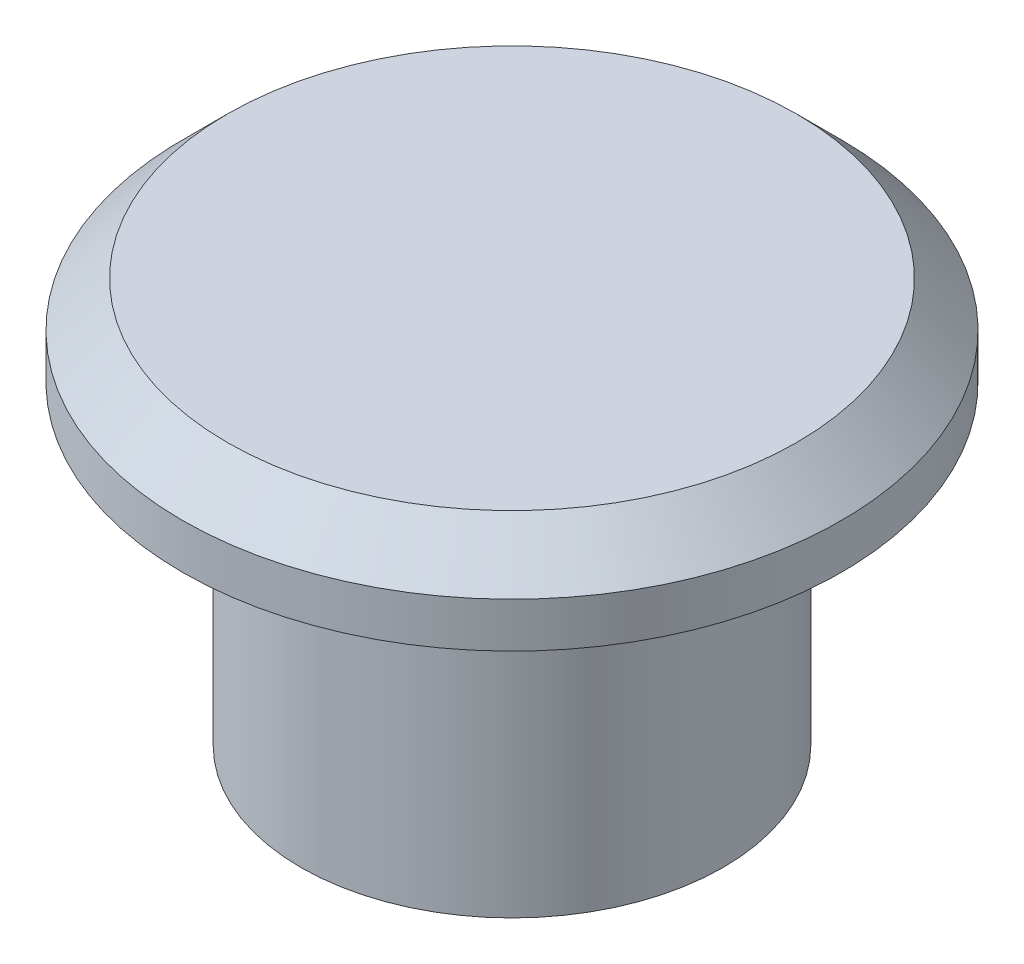
from build123d import *

# Parameters (mm, degrees)
SKETCH1_R           = 4.7
BOSS_EXTRUDE1_DEPTH = 7
SKETCH2_R           = 3.506998357
CUT_EXTRUDE1_DEPTH  = 7
SKETCH3_R           = 7.330684461
BOSS_EXTRUDE2_DEPTH = 2
CHAMFER1_SIZE       = 1


with BuildPart() as part:
    # Sketch1 → Boss-Extrude1 (new body)
    with BuildSketch(Plane(origin=(0, 0, 0), x_dir=(1, 0, 0), z_dir=(0, 1, 0))):
        Circle(SKETCH1_R)
    extrude(amount=BOSS_EXTRUDE1_DEPTH)

    # Sketch2 → Cut-Extrude1 (cut)
    with BuildSketch(Plane(origin=(0, 7, 0), x_dir=(-1, 0, 0), z_dir=(0, 1, 0))):
        Circle(SKETCH2_R)
    extrude(amount=-CUT_EXTRUDE1_DEPTH, mode=Mode.SUBTRACT)

    # Sketch3 → Boss-Extrude2 (add)
    with BuildSketch(Plane(origin=(0, 7, 0), x_dir=(1, 0, 0), z_dir=(0, 1, 0))):
        Circle(SKETCH3_R)
    extrude(amount=BOSS_EXTRUDE2_DEPTH)

    # Chamfer1
    chamfer1_edges = [part.edges().sort_by_distance(p)[0] for p in [
        (-7.330684461, 9, 0),
    ]]
    chamfer(chamfer1_edges, length=CHAMFER1_SIZE)


solid = part.part
